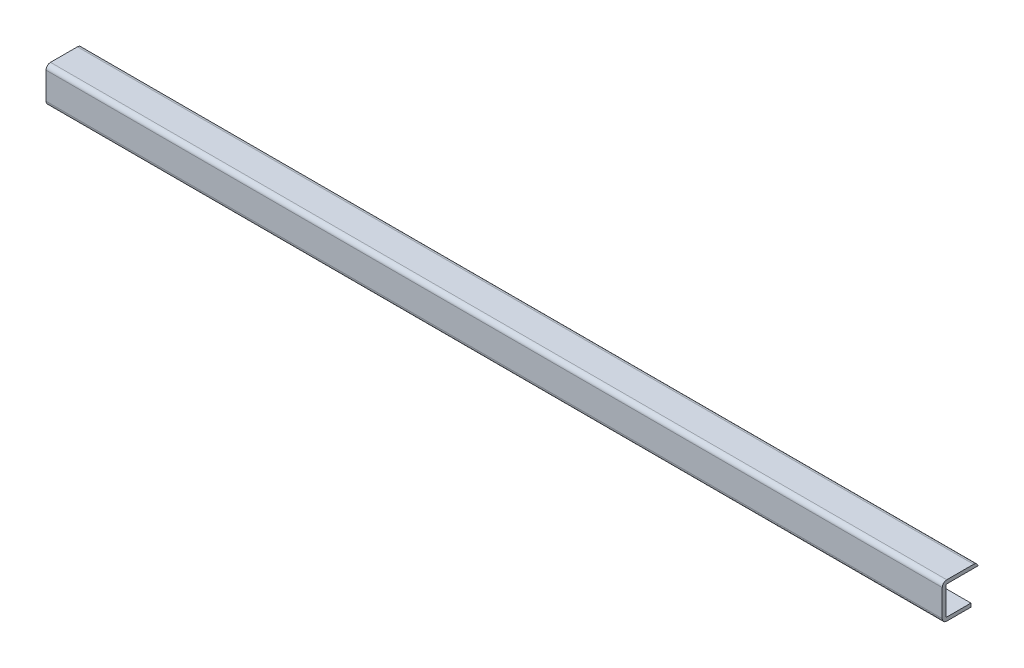
from build123d import *

# Parameters (mm, degrees)
EXTRUDE_1_DEPTH     = 1000
SKETCH_2_W          = 8.555369223
SKETCH_2_H          = 36.536948801
CUT_EXTRUDE_1_DEPTH = 1001


with BuildPart() as part:
    # Эскиз1 → Вытянуть-Тонкостенный1 (new body)
    with BuildSketch(Plane(origin=(0, 0, 0), x_dir=(0, 0, -1), z_dir=(1, 0, 0))):
        with BuildLine():
            Line((-4, 31), (-4, 1))
            ThreePointArc((-4, 1), (-2.535533906, -2.535533906), (1, -4))
            Line((1, -4), (31, -4))
            ThreePointArc((31, -4), (34.535533906, -2.535533906), (36, 1))
            Line((36, 1), (36, 31))
            ThreePointArc((36, 31), (34.535533906, 34.535533906), (31, 36))
            Line((31, 36), (1, 36))
            ThreePointArc((1, 36), (-2.535533906, 34.535533906), (-4, 31))
        make_face()
        with BuildLine():
            Line((0, 31), (0, 1))
            ThreePointArc((0, 1), (0.292893219, 0.292893219), (1, 0))
            Line((1, 0), (31, 0))
            ThreePointArc((31, 0), (31.707106781, 0.292893219), (32, 1))
            Line((32, 1), (32, 31))
            ThreePointArc((32, 31), (31.707106781, 31.707106781), (31, 32))
            Line((31, 32), (1, 32))
            ThreePointArc((1, 32), (0.292893219, 31.707106781), (0, 31))
        make_face(mode=Mode.SUBTRACT)
    extrude(amount=EXTRUDE_1_DEPTH)

    # Эскиз2 → Вырез-Вытянуть1 (cut, through all)
    with BuildSketch(Plane(origin=(1000, 0, 0), x_dir=(0, 0, -1), z_dir=(1, 0, 0))):
        with Locations((32.277684611, 13.731525599)):
            Rectangle(SKETCH_2_W, SKETCH_2_H)
    extrude(amount=-CUT_EXTRUDE_1_DEPTH, mode=Mode.SUBTRACT)


solid = part.part
